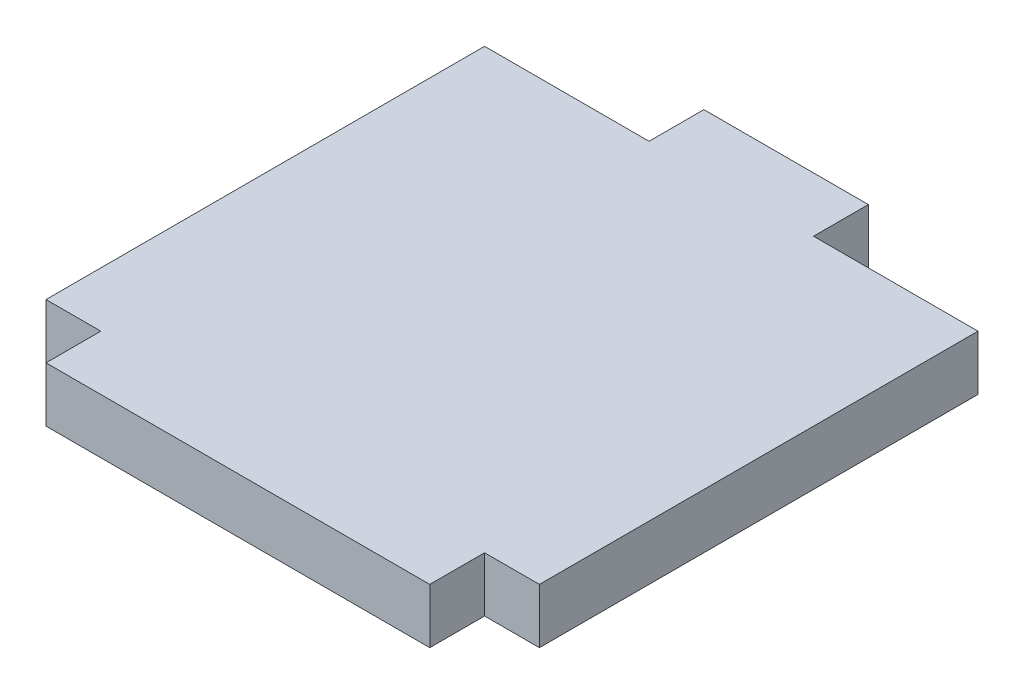
from build123d import *

# Parameters (mm, degrees)
SKETCH_1_W      = 45
SKETCH_1_H      = 40
SKETCH_1_W_2    = 35
SKETCH_1_H_2    = 5
EXTRUDE_1_DEPTH = 5
SKETCH_2_W      = 15
SKETCH_2_H      = 5
EXTRUDE_2_DEPTH = 5


with BuildPart() as part:
    # 草图1 → 凸台-拉伸1 (new body)
    with BuildSketch(Plane(origin=(0, 0, 0), x_dir=(1, 0, 0), z_dir=(0, 1, 0))):
        Rectangle(SKETCH_1_W, SKETCH_1_H)
        with Locations((0, -22.5)):
            Rectangle(SKETCH_1_W_2, SKETCH_1_H_2)
    extrude(amount=EXTRUDE_1_DEPTH)

    # 草图2 → 凸台-拉伸2 (add)
    with BuildSketch(Plane(origin=(0, 5, 0), x_dir=(1, 0, 0), z_dir=(0, 1, 0))):
        with Locations((0, 22.5)):
            Rectangle(SKETCH_2_W, SKETCH_2_H)
    extrude(amount=-EXTRUDE_2_DEPTH)


solid = part.part
